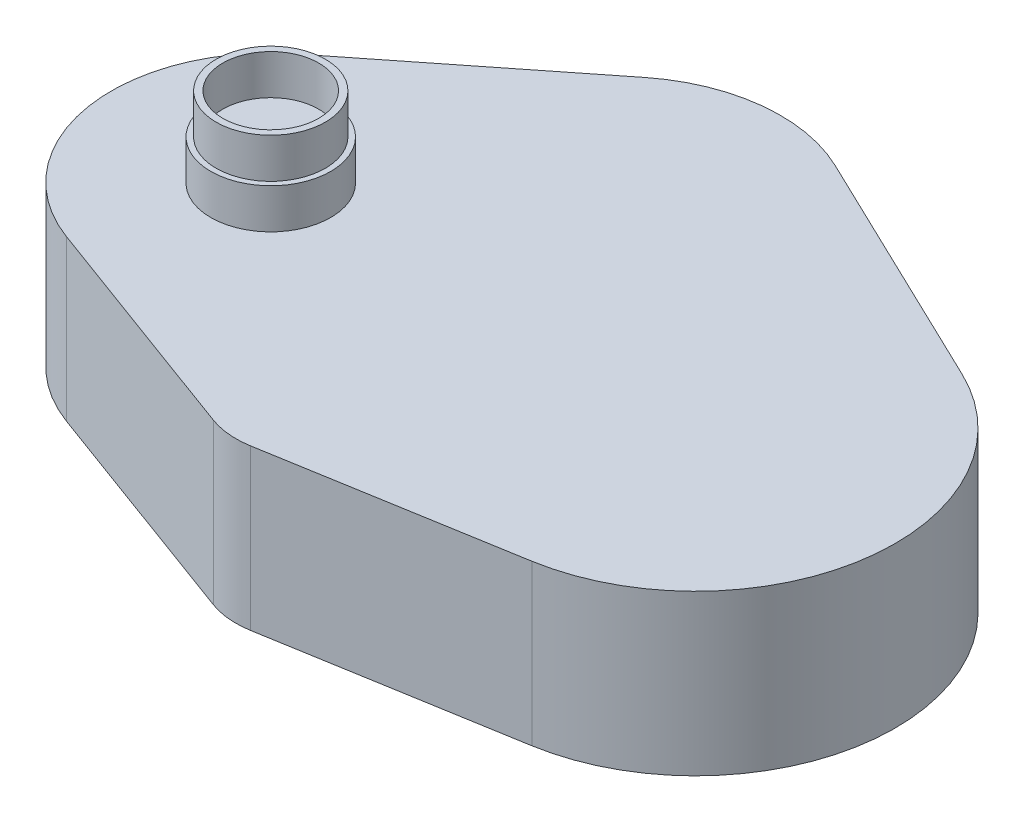
from build123d import *

# Parameters (mm, degrees)
BOSS_EXTRUDE1_DEPTH = 20
SKETCH2_R           = 7.5
BOSS_EXTRUDE2_DEPTH = 5
SKETCH3_R           = 6.829132763
SKETCH3_R_2         = 6
BOSS_EXTRUDE3_DEPTH = 5


with BuildPart() as part:
    # Sketch1 → Boss-Extrude1 (new body)
    with BuildSketch(Plane(origin=(0, 0, 0), x_dir=(1, 0, 0), z_dir=(0, 1, 0))):
        with BuildLine():
            Line((-31.046293844, -29.276824699), (-60.108766173, -18.587025627))
            ThreePointArc((-60.108766173, -18.587025627), (-72.82850904, -3.124641863), (-65.560050374, 15.531367327))
            Line((-65.560050374, 15.531367327), (-41.175993118, 34.823361534))
            ThreePointArc((-41.175993118, 34.823361534), (-30.799217935, 39.089909616), (-19.738248933, 37.20952123))
            Line((-19.738248933, 37.20952123), (10.820861573, 22.53683551))
            ThreePointArc((10.820861573, 22.53683551), (24.755892372, -3.485081474), (4.178228718, -24.648375297))
            Line((4.178228718, -24.648375297), (-25.922904595, -29.750919304))
            ThreePointArc((-25.922904595, -29.750919304), (-28.515613019, -29.84902824), (-31.046293844, -29.276824699))
        make_face()
    extrude(amount=BOSS_EXTRUDE1_DEPTH)

    # Sketch2 → Boss-Extrude2 (add)
    with BuildSketch(Plane(origin=(0, 20, 0), x_dir=(1, 0, 0), z_dir=(0, 1, 0))):
        with Locations((-53.129573655, 0)):
            Circle(SKETCH2_R)
    extrude(amount=BOSS_EXTRUDE2_DEPTH)

    # Sketch3 → Boss-Extrude3 (add)
    with BuildSketch(Plane(origin=(0, 25, 0), x_dir=(1, 0, 0), z_dir=(0, 1, 0))):
        with Locations((-53.129573655, 0)):
            Circle(SKETCH3_R)
        with Locations((-53.129573655, 0)):
            Circle(SKETCH3_R_2, mode=Mode.SUBTRACT)
    extrude(amount=BOSS_EXTRUDE3_DEPTH)


solid = part.part
